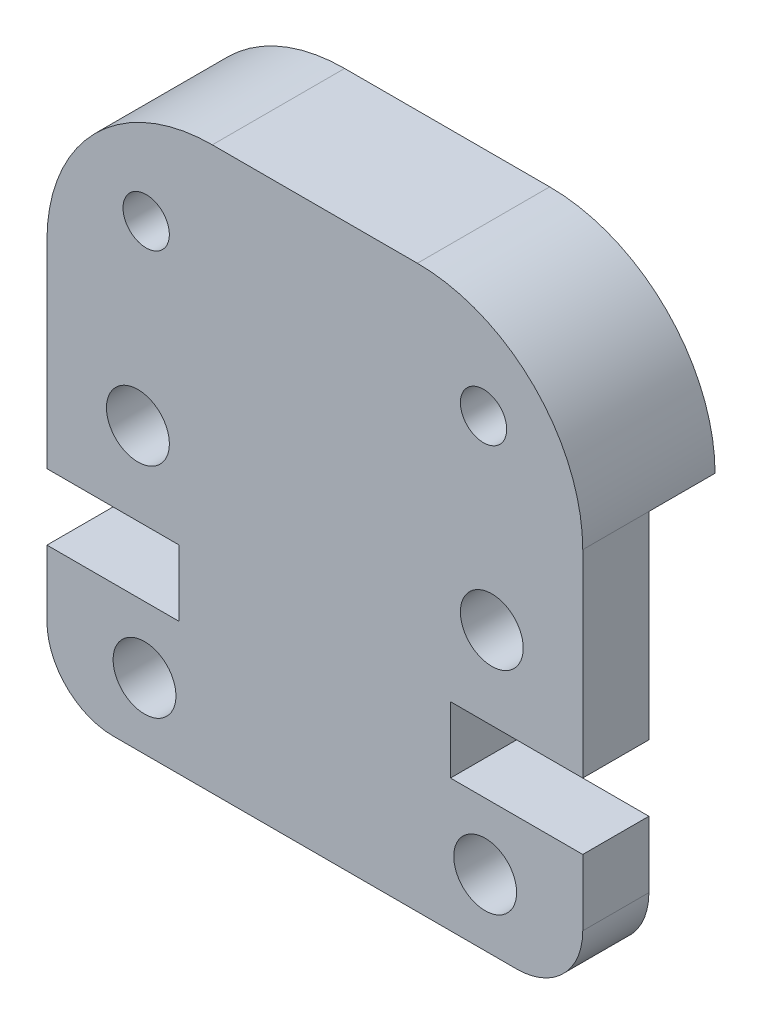
from build123d import *

# Parameters (mm, degrees)
SKETCH1_R           = 0.95
SKETCH1_R_2         = 0.7
BOSS_EXTRUDE1_DEPTH = 4
SKETCH2_W           = 16.2
SKETCH2_H           = 11.98
CUT_EXTRUDE1_DEPTH  = 2


with BuildPart() as part:
    # Sketch1 → Boss-Extrude1 (new body)
    with BuildSketch(Plane.XY):
        with BuildLine():
            Line((3.1, 16.98), (-3.1, 16.98))
            ThreePointArc((-3.1, 16.98), (-6.635533906, 15.515533906), (-8.1, 11.98))
            Line((-8.1, 11.98), (-8.1, 6))
            Line((-8.1, 6), (-4.1, 6))
            Line((-4.1, 6), (-4.1, 4))
            Line((-4.1, 4), (-8.1, 4))
            Line((-8.1, 4), (-8.1, 2))
            ThreePointArc((-8.1, 2), (-7.514213562, 0.585786438), (-6.1, 0))
            Line((-6.1, 0), (6.1, 0))
            ThreePointArc((6.1, 0), (7.514213562, 0.585786438), (8.1, 2))
            Line((8.1, 2), (8.1, 4))
            Line((8.1, 4), (4.1, 4))
            Line((4.1, 4), (4.1, 6))
            Line((4.1, 6), (8.1, 6))
            Line((8.1, 6), (8.1, 11.98))
            ThreePointArc((8.1, 11.98), (6.635533906, 15.515533906), (3.1, 16.98))
        make_face()
        with Locations((-5.15, 2)):
            Circle(SKETCH1_R, mode=Mode.SUBTRACT)
        with Locations((-5.1, 13.98)):
            Circle(SKETCH1_R_2, mode=Mode.SUBTRACT)
        with Locations((-5.35, 8.5)):
            Circle(SKETCH1_R, mode=Mode.SUBTRACT)
        with Locations((5.35, 8.5)):
            Circle(SKETCH1_R, mode=Mode.SUBTRACT)
        with Locations((5.1, 13.98)):
            Circle(SKETCH1_R_2, mode=Mode.SUBTRACT)
        with Locations((5.15, 2)):
            Circle(SKETCH1_R, mode=Mode.SUBTRACT)
    extrude(amount=BOSS_EXTRUDE1_DEPTH)

    # Sketch2 → Cut-Extrude1 (cut)
    with BuildSketch(Plane.XY):
        with Locations((0, 5.99)):
            Rectangle(SKETCH2_W, SKETCH2_H)
    extrude(amount=CUT_EXTRUDE1_DEPTH, mode=Mode.SUBTRACT)


solid = part.part
